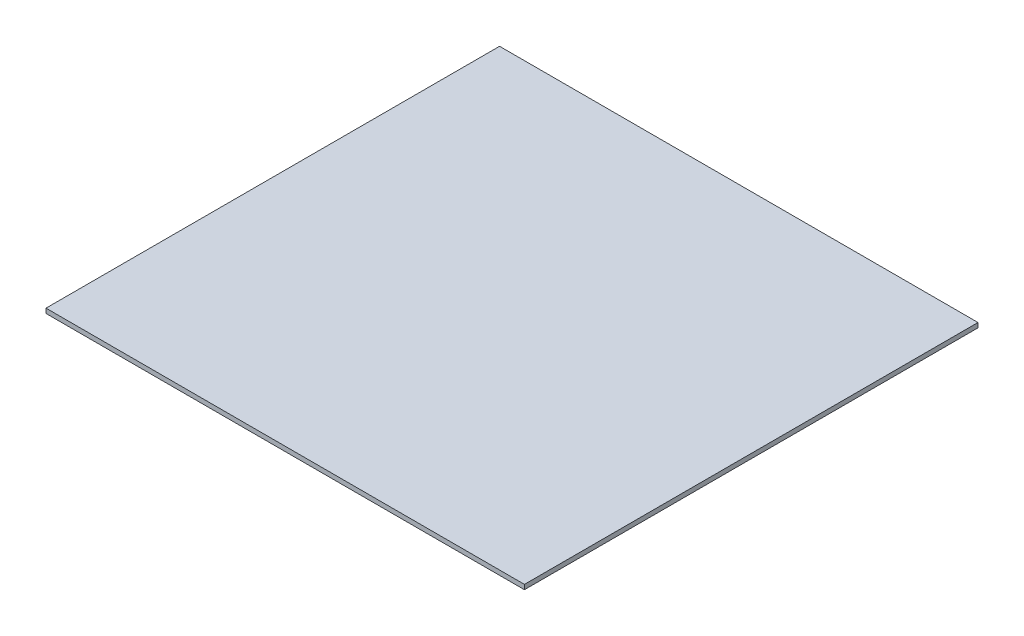
from build123d import *

# Parameters (mm, degrees)
SKETCH1_W           = 327
SKETCH1_H           = 310
BOSS_EXTRUDE1_DEPTH = 3.175


with BuildPart() as part:
    # Sketch1 → Boss-Extrude1 (new body)
    with BuildSketch(Plane(origin=(0, 0, 0), x_dir=(1, 0, 0), z_dir=(0, 1, 0))):
        Rectangle(SKETCH1_W, SKETCH1_H)
    extrude(amount=BOSS_EXTRUDE1_DEPTH)


solid = part.part
